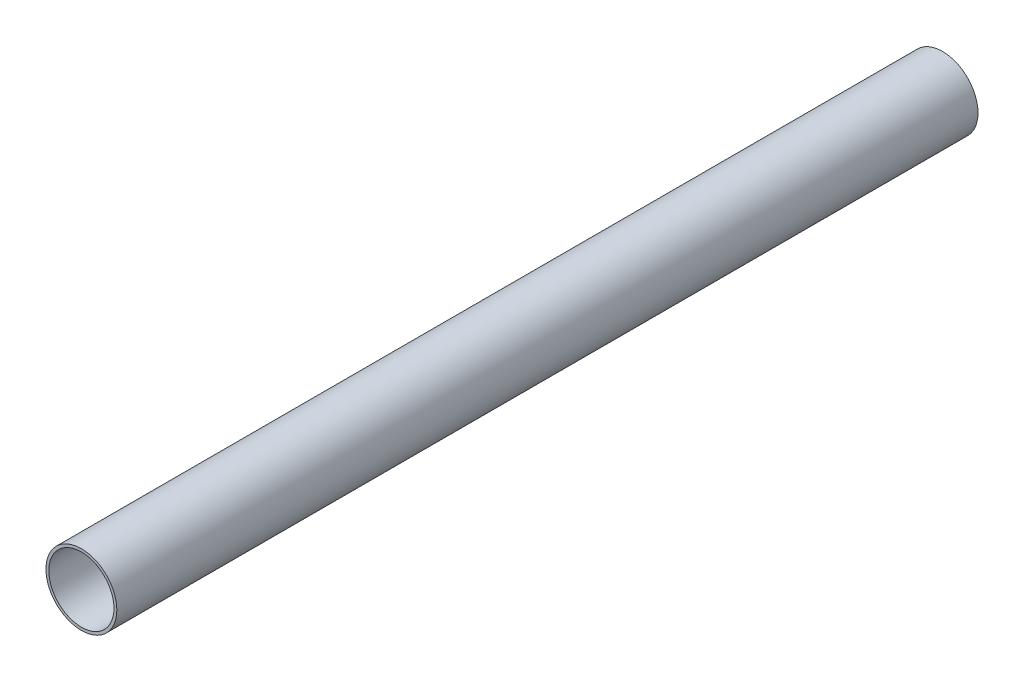
from build123d import *

# Parameters (mm, degrees)
SKETCH1_R           = 12.35
SKETCH1_R_2         = 11.35
BOSS_EXTRUDE1_DEPTH = 300


with BuildPart() as part:
    # Sketch1 → Boss-Extrude1 (new body)
    with BuildSketch(Plane.XY):
        Circle(SKETCH1_R)
        Circle(SKETCH1_R_2, mode=Mode.SUBTRACT)
    extrude(amount=BOSS_EXTRUDE1_DEPTH)


solid = part.part
